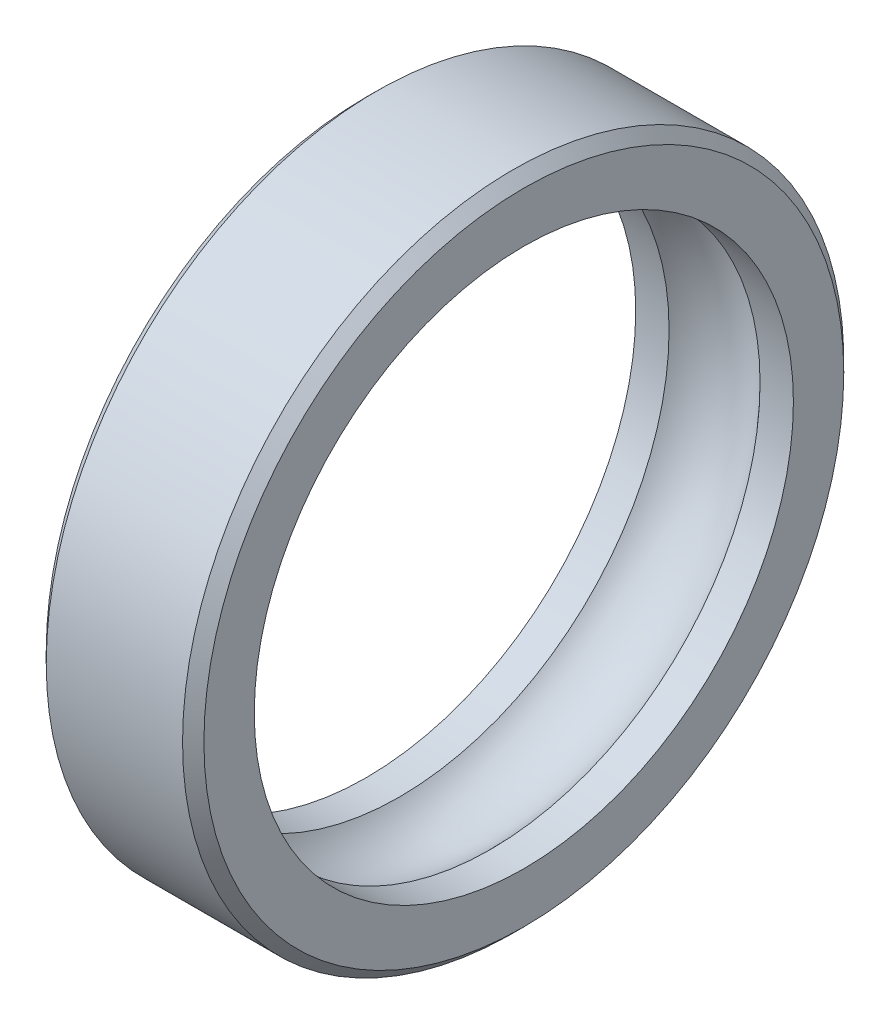
from build123d import *

# Parameters (mm, degrees)
CHAMFER1_SIZE = 2.1


with BuildPart() as part:
    # Sketch1 → Revolve1 (revolve)
    with BuildSketch(Plane.XY):
        with BuildLine():
            Line((-15.5, 65), (15.5, 65))
            Line((15.5, 65), (15.5, 53))
            Line((15.5, 53), (8.94427191, 53))
            ThreePointArc((8.94427191, 53), (0, 57), (-8.94427191, 53))
            Line((-8.94427191, 53), (-15.5, 53))
            Line((-15.5, 53), (-15.5, 65))
        make_face()
    revolve(axis=Axis((-47.365464456, 0, 0), (1, 0, 0)))

    # Chamfer1
    chamfer1_edges = [part.edges().sort_by_distance(p)[0] for p in [
        (15.5, -65, 0),
        (-15.5, -65, 0),
    ]]
    chamfer(chamfer1_edges, length=CHAMFER1_SIZE)


solid = part.part
